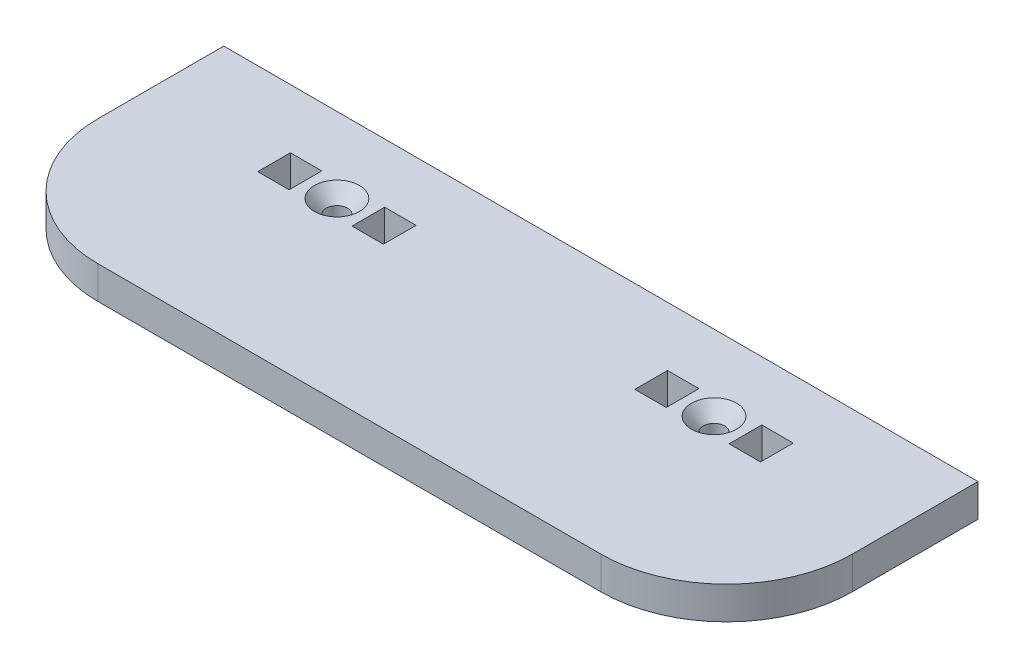
from build123d import *

# Parameters (mm, degrees)
SKETCH1_W                                         = 152.4
SKETCH1_H                                         = 50.8
BOSS_EXTRUDE1_DEPTH                               = 6.604
FILLET1_R                                         = 25.4
SKETCH2_R                                         = 2.15265
SKETCH2_W                                         = 6.35
SKETCH2_H                                         = 6.604
CUT_EXTRUDE1_DEPTH                                = 7.604
CSK_FOR_8_FLAT_HEAD_SOCKET_CAP_SCREW1_D           = 4.3053
CSK_FOR_8_FLAT_HEAD_SOCKET_CAP_SCREW1_CSINK_D     = 9.1186
CSK_FOR_8_FLAT_HEAD_SOCKET_CAP_SCREW1_CSINK_ANGLE = 82


with BuildPart() as part:
    # Sketch1 → Boss-Extrude1 (new body)
    with BuildSketch(Plane(origin=(0, 0, 0), x_dir=(1, 0, 0), z_dir=(0, 1, 0))):
        Rectangle(SKETCH1_W, SKETCH1_H)
    extrude(amount=BOSS_EXTRUDE1_DEPTH)

    # Fillet1
    fillet1_edges = [part.edges().sort_by_distance(p)[0] for p in [
        (76.2, 3.302, 25.4),
        (-76.2, 3.302, 25.4),
    ]]
    fillet(fillet1_edges, radius=FILLET1_R)

    # Sketch2 → Cut-Extrude1 (cut, through all)
    with BuildSketch(Plane(origin=(0, 6.604, 0), x_dir=(1, 0, 0), z_dir=(0, 1, 0))):
        with Locations((-38.1, 10.16)):
            Circle(SKETCH2_R)
        with Locations((38.1, 10.16)):
            Circle(SKETCH2_R)
        with Locations((-28.575, 10.16)):
            Rectangle(SKETCH2_W, SKETCH2_H)
        with Locations((-47.625, 10.16)):
            Rectangle(SKETCH2_W, SKETCH2_H)
        with Locations((47.625, 10.16)):
            Rectangle(SKETCH2_W, SKETCH2_H)
        with Locations((28.575, 10.16)):
            Rectangle(SKETCH2_W, SKETCH2_H)
    extrude(amount=-CUT_EXTRUDE1_DEPTH, mode=Mode.SUBTRACT)

    # CSK for #8 Flat Head Socket Cap Screw1 (through all)
    with Locations(Plane(origin=(0, 6.604, 0), x_dir=(1, 0, 0), z_dir=(0, 1, 0))):
        with Locations((-38.1, 10.16), (38.1, 10.16)):
            CounterSinkHole(CSK_FOR_8_FLAT_HEAD_SOCKET_CAP_SCREW1_D / 2, CSK_FOR_8_FLAT_HEAD_SOCKET_CAP_SCREW1_CSINK_D / 2, counter_sink_angle=CSK_FOR_8_FLAT_HEAD_SOCKET_CAP_SCREW1_CSINK_ANGLE)


solid = part.part
